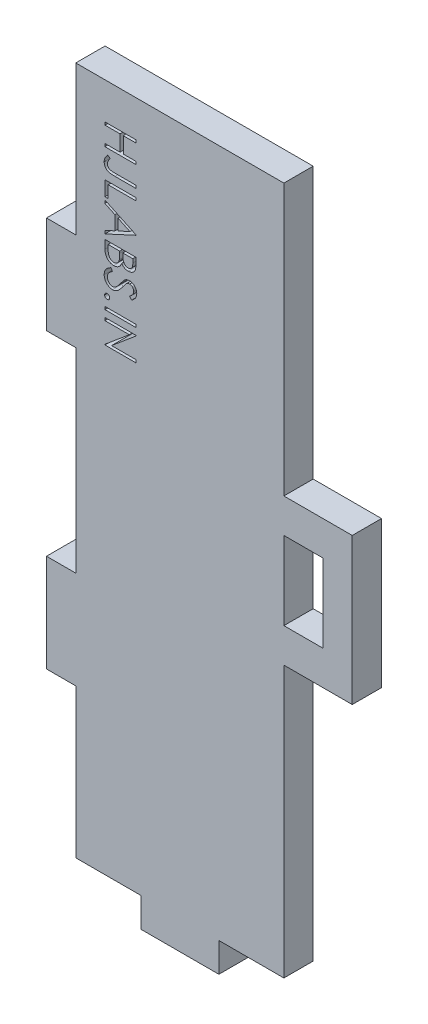
from build123d import *

# Parameters (mm, degrees)
SKETCH1_W           = 4
SKETCH1_H           = 8
BOSS_EXTRUDE1_DEPTH = 3
SKETCH6_W           = 3.175
SKETCH6_H           = 0.284935898
CUT_EXTRUDE2_DEPTH  = 3
SKETCH7_W           = 8
SKETCH7_H           = 3
BOSS_EXTRUDE2_DEPTH = 3


with BuildPart() as part:
    # Sketch1 → Boss-Extrude1 (new body)
    with BuildSketch(Plane.XY):
        Polygon((-24.311841589, 19.25), (-21.311841589, 19.25), (-21.311841589, -0.75), (-24.311841589, -0.75), (-24.311841589, -10.75), (-21.311841589, -10.75), (-21.311841589, -26), (-19.311841589, -26), (-2, -26), (0, -26), (0, 1.75), (7, 1.75), (7, 16.75), (0, 16.75), (0, 44.5), (-2, 44.5), (-19.311841589, 44.5), (-21.311841589, 44.5), (-21.311841589, 29.25), (-24.311841589, 29.25), align=None)
        with Locations((2, 9.25)):
            Rectangle(SKETCH1_W, SKETCH1_H, mode=Mode.SUBTRACT)
    extrude(amount=BOSS_EXTRUDE1_DEPTH)

    # Sketch6 → Cut-Extrude2 (cut)
    with BuildSketch(Plane.XY.offset(3)):
        Polygon((-15.146593803, 40.762402334), (-15.146593803, 40.477466437), (-16.449157905, 40.477466437), (-16.449157905, 38.849261309), (-15.146593803, 38.849261309), (-15.146593803, 38.564325411), (-18.321593803, 38.564325411), (-18.321593803, 38.849261309), (-16.774798931, 38.849261309), (-16.774798931, 40.477466437), (-18.321593803, 40.477466437), (-18.321593803, 40.762402334), align=None)
        with BuildLine():
            Line((-15.146593803, 36.732594642), (-15.146593803, 36.447658745))
            Line((-15.146593803, 36.447658745), (-17.290609227, 36.447658745))
            add(Edge.make_bspline(
                [(-17.290609227, 36.447658745), (-17.330256371, 36.447941117), (-17.406383724, 36.448483308), (-17.516029536, 36.451521507), (-17.616165112, 36.456980275), (-17.706916062, 36.465421839), (-17.788266276, 36.475147508), (-17.860486348, 36.487764385), (-17.923217614, 36.502682774), (-17.99362352, 36.525281608), (-18.071094596, 36.562131291), (-18.154094048, 36.618630687), (-18.227288813, 36.687655753), (-18.290615692, 36.767815595), (-18.341115688, 36.859548851), (-18.377357691, 36.961061014), (-18.399466395, 37.071700873), (-18.401801173, 37.148444623), (-18.403004059, 37.187983264)],
                knots=[0, 0, 0, 0, 0.000118942, 0.000228383, 0.000329037, 0.000419729, 0.000501773, 0.00057476, 0.00063955, 0.000695062, 0.000796347, 0.000895665, 0.000995106, 0.001097022, 0.001200928, 0.001307758, 0.00141927, 0.001537776, 0.001537776, 0.001537776, 0.001537776], degree=3))
            add(Edge.make_bspline(
                [(-18.403004059, 37.187983264), (-18.402055378, 37.219005494), (-18.400159525, 37.281000581), (-18.383770011, 37.373392277), (-18.359467235, 37.465306663), (-18.322718594, 37.557356332), (-18.273584158, 37.651488172), (-18.208969796, 37.749059064), (-18.129306243, 37.851228826), (-18.068491626, 37.918523007), (-18.036657905, 37.953748488)],
                knots=[0, 0, 0, 0, 9.2998e-05, 0.000185848, 0.000280734, 0.000377818, 0.000482504, 0.000598756, 0.000728394, 0.000870794, 0.000870794, 0.000870794, 0.000870794], degree=3))
            Line((-18.036657905, 37.953748488), (-17.792427136, 37.785839834))
            add(Edge.make_bspline(
                [(-17.792427136, 37.785839834), (-17.81909048, 37.747072521), (-17.869331986, 37.67402361), (-17.934848734, 37.566898954), (-17.989919083, 37.471326054), (-18.018412739, 37.408890418), (-18.031569764, 37.380060588)],
                knots=[0, 0, 0, 0, 0.000141121, 0.000265914, 0.000376678, 0.0004717, 0.0004717, 0.0004717, 0.0004717], degree=3))
            add(Edge.make_bspline(
                [(-18.031569764, 37.380060588), (-18.038427272, 37.362566962), (-18.051876372, 37.328258067), (-18.066885865, 37.275802459), (-18.075088623, 37.223646247), (-18.076613832, 37.189068053), (-18.077363034, 37.172082823)],
                knots=[0, 0, 0, 0, 5.6351e-05, 0.000110517, 0.000163322, 0.000214303, 0.000214303, 0.000214303, 0.000214303], degree=3))
            add(Edge.make_bspline(
                [(-18.077363034, 37.172082823), (-18.076464414, 37.150137454), (-18.074696621, 37.106965815), (-18.058149486, 37.044071193), (-18.033889336, 36.983615137), (-17.997485534, 36.928089252), (-17.9544811, 36.877038154), (-17.902471274, 36.83483933), (-17.844634614, 36.799948039), (-17.790324267, 36.777897586), (-17.740406505, 36.764599203), (-17.694730457, 36.755790989), (-17.641119468, 36.749416413), (-17.579911119, 36.742548324), (-17.510685412, 36.738848676), (-17.433760947, 36.734533594), (-17.34891625, 36.732997556), (-17.289760825, 36.732733045), (-17.258808346, 36.732594642)],
                knots=[0, 0, 0, 0, 6.5707e-05, 0.000129261, 0.000193988, 0.00026033, 0.000327522, 0.000393484, 0.000460239, 0.000529568, 0.000568448, 0.000615099, 0.00066898, 0.000730369, 0.000799837, 0.00087689, 0.000961502, 0.001054363, 0.001054363, 0.001054363, 0.001054363], degree=3))
            Line((-17.258808346, 36.732594642), (-15.146593803, 36.732594642))
        make_face()
        Polygon((-15.146593803, 35.63355618), (-15.146593803, 35.348620283), (-17.995952777, 35.348620283), (-17.995952777, 34.127466437), (-18.321593803, 34.127466437), (-18.321593803, 35.63355618), align=None)
        Polygon((-15.146593803, 32.295735668), (-18.321593803, 30.830351052), (-18.321593803, 31.140091637), (-17.303965598, 31.609472647), (-17.303965598, 33.048780539), (-18.321593803, 33.531517919), (-18.321593803, 33.842530539), (-15.146593803, 32.336440796), align=None)
        Polygon((-15.765438955, 32.31926832), (-16.978324572, 32.894228256), (-16.978324572, 31.759572807), align=None, mode=Mode.SUBTRACT)
        with BuildLine():
            Line((-15.146593803, 30.341889514), (-15.146593803, 29.722408344))
            add(Edge.make_bspline(
                [(-15.146593803, 29.722408344), (-15.146753234, 29.692083939), (-15.14706225, 29.633307694), (-15.151854805, 29.547837201), (-15.158389562, 29.467782922), (-15.168758289, 29.393121643), (-15.181269401, 29.323887863), (-15.196420334, 29.259872935), (-15.214587334, 29.201280422), (-15.243476461, 29.131328154), (-15.286405335, 29.051571554), (-15.349840533, 28.965213012), (-15.427430696, 28.891367738), (-15.514954248, 28.827698722), (-15.611234555, 28.777079135), (-15.713976819, 28.740458415), (-15.821855828, 28.717273771), (-15.895917854, 28.714889405), (-15.933347609, 28.713684386)],
                knots=[0, 0, 0, 0, 9.0959e-05, 0.000176302, 0.000256745, 0.000331852, 0.000402335, 0.000467743, 0.000529095, 0.000586142, 0.000694565, 0.000800018, 0.00090617, 0.001014562, 0.001123809, 0.001231237, 0.001341005, 0.001453163, 0.001453163, 0.001453163, 0.001453163], degree=3))
            add(Edge.make_bspline(
                [(-15.933347609, 28.713684386), (-15.96841694, 28.714656924), (-16.037331482, 28.716568054), (-16.137964258, 28.735465339), (-16.234152744, 28.7636007), (-16.324711134, 28.804444931), (-16.408475558, 28.856983252), (-16.484948206, 28.920207057), (-16.552275828, 28.995483263), (-16.589758719, 29.051972556), (-16.60879833, 29.080666557)],
                knots=[0, 0, 0, 0, 0.000105099, 0.000206529, 0.000306133, 0.000405196, 0.000503491, 0.000601945, 0.000701931, 0.00080515, 0.00080515, 0.00080515, 0.00080515], degree=3))
            add(Edge.make_bspline(
                [(-16.60879833, 29.080666557), (-16.622635179, 29.044592129), (-16.649108498, 28.975572811), (-16.696167685, 28.880524818), (-16.746774708, 28.798306195), (-16.802332621, 28.728826443), (-16.862967023, 28.670300504), (-16.927463745, 28.617742996), (-16.99899805, 28.573711588), (-17.075533049, 28.535884897), (-17.15653158, 28.506115688), (-17.241623207, 28.485052019), (-17.32985645, 28.47210942), (-17.389996372, 28.470344567), (-17.420356824, 28.469453616)],
                knots=[0, 0, 0, 0, 0.000115862, 0.000221672, 0.000317675, 0.000404986, 0.000487741, 0.000570085, 0.000654088, 0.000739136, 0.000825861, 0.000912399, 0.001001716, 0.001092775, 0.001092775, 0.001092775, 0.001092775], degree=3))
            add(Edge.make_bspline(
                [(-17.420356824, 28.469453616), (-17.451350882, 28.470340033), (-17.51233256, 28.472084084), (-17.601920085, 28.484943372), (-17.687522418, 28.50673766), (-17.769748205, 28.536684203), (-17.848132018, 28.575990279), (-17.923655549, 28.622793574), (-17.994306902, 28.679759115), (-18.061766244, 28.743255274), (-18.122384589, 28.815171504), (-18.176351748, 28.89275223), (-18.220937809, 28.977113318), (-18.257923037, 29.066946549), (-18.286586399, 29.16284887), (-18.306485834, 29.264464697), (-18.319925319, 29.371816112), (-18.321028205, 29.445485488), (-18.321593803, 29.483265716)],
                knots=[0, 0, 0, 0, 9.2965e-05, 0.000182912, 0.000270839, 0.000357564, 0.000444886, 0.000533473, 0.000623565, 0.000716687, 0.000810992, 0.0009052, 0.000999667, 0.001096636, 0.001196239, 0.001299394, 0.001406999, 0.001520275, 0.001520275, 0.001520275, 0.001520275], degree=3))
            Line((-18.321593803, 29.483265716), (-18.321593803, 30.341889514))
            Line((-18.321593803, 30.341889514), (-15.146593803, 30.341889514))
        make_face()
        with BuildLine():
            Line((-15.472234828, 30.056953616), (-16.489863034, 30.056953616))
            Line((-16.489863034, 30.056953616), (-16.489863034, 29.86551231))
            add(Edge.make_bspline(
                [(-16.489863034, 29.86551231), (-16.489503265, 29.837527794), (-16.488808119, 29.783456005), (-16.486754095, 29.704943434), (-16.481254599, 29.632247438), (-16.475437973, 29.565117519), (-16.46648156, 29.504003612), (-16.455521428, 29.448701124), (-16.444031419, 29.398713265), (-16.424436042, 29.341092486), (-16.395769755, 29.275751287), (-16.350235919, 29.206537817), (-16.297475052, 29.144529828), (-16.235473139, 29.092753938), (-16.167780787, 29.050029779), (-16.09439196, 29.021517529), (-16.018171733, 29.001294165), (-15.965708514, 28.999520707), (-15.939071768, 28.998620283)],
                knots=[0, 0, 0, 0, 8.3964e-05, 0.000162235, 0.000235554, 0.000302638, 0.000364342, 0.000420722, 0.000471782, 0.000518041, 0.000603156, 0.000685012, 0.000765726, 0.00084651, 0.000926469, 0.001004655, 0.001081939, 0.001161647, 0.001161647, 0.001161647, 0.001161647], degree=3))
            add(Edge.make_bspline(
                [(-15.939071768, 28.998620283), (-15.921441518, 28.999070623), (-15.886857858, 28.999954014), (-15.83663704, 29.007993922), (-15.788799938, 29.019659906), (-15.744446774, 29.037885732), (-15.702316904, 29.059924523), (-15.664281597, 29.088592991), (-15.628257053, 29.120969412), (-15.595566003, 29.158992367), (-15.566274695, 29.202477746), (-15.540500912, 29.251839886), (-15.520169816, 29.307668196), (-15.50193174, 29.368696831), (-15.489276503, 29.435902501), (-15.478695039, 29.508628516), (-15.473316189, 29.587491831), (-15.472603322, 29.642051872), (-15.472234828, 29.670254898)],
                knots=[0, 0, 0, 0, 5.2851e-05, 0.000103672, 0.000152264, 0.000200215, 0.000247169, 0.000294491, 0.000342665, 0.000392266, 0.000444482, 0.000499669, 0.000558849, 0.000622451, 0.000690555, 0.000763772, 0.000842846, 0.000927458, 0.000927458, 0.000927458, 0.000927458], degree=3))
            Line((-15.472234828, 29.670254898), (-15.472234828, 30.056953616))
        make_face(mode=Mode.SUBTRACT)
        with BuildLine():
            Line((-16.815504059, 30.056953616), (-17.995952777, 30.056953616))
            Line((-17.995952777, 30.056953616), (-17.995952777, 29.65117437))
            add(Edge.make_bspline(
                [(-17.995952777, 29.65117437), (-17.995605879, 29.622128486), (-17.994937279, 29.566146373), (-17.992730751, 29.485320746), (-17.987817139, 29.410609941), (-17.979806642, 29.341970967), (-17.971483037, 29.278799614), (-17.959962766, 29.221723491), (-17.946865611, 29.170655097), (-17.926597142, 29.111447524), (-17.895163465, 29.044733185), (-17.847459494, 28.972888559), (-17.791375914, 28.908375034), (-17.725648023, 28.854219161), (-17.654721262, 28.809499364), (-17.578966601, 28.778134762), (-17.500695089, 28.757967772), (-17.447190155, 28.755584668), (-17.420356824, 28.754389514)],
                knots=[0, 0, 0, 0, 8.7144e-05, 0.000167958, 0.000242546, 0.000311658, 0.000375251, 0.000433626, 0.000486231, 0.000533296, 0.00062121, 0.000706588, 0.000791309, 0.000876652, 0.000961195, 0.001041871, 0.001121777, 0.001202167, 0.001202167, 0.001202167, 0.001202167], degree=3))
            add(Edge.make_bspline(
                [(-17.420356824, 28.754389514), (-17.403578551, 28.7546338), (-17.370292642, 28.755118431), (-17.321414934, 28.762702092), (-17.273857435, 28.773281793), (-17.228339281, 28.788602111), (-17.184119797, 28.807919789), (-17.141969216, 28.832162743), (-17.100879703, 28.860158762), (-17.048992959, 28.903953786), (-16.989190268, 28.967594294), (-16.930647722, 29.058047768), (-16.883432307, 29.160891175), (-16.863385013, 29.235483466), (-16.853029099, 29.274015916)],
                knots=[0, 0, 0, 0, 5.0282e-05, 9.9752e-05, 0.000148043, 0.000196314, 0.000243585, 0.000292575, 0.000341972, 0.000392542, 0.000496043, 0.000602591, 0.000714445, 0.000833969, 0.000833969, 0.000833969, 0.000833969], degree=3))
            add(Edge.make_bspline(
                [(-16.853029099, 29.274015916), (-16.849894634, 29.289463724), (-16.843098466, 29.322957759), (-16.835929101, 29.377574913), (-16.829497947, 29.440137248), (-16.824865719, 29.510377361), (-16.819893104, 29.588574606), (-16.81802807, 29.674703862), (-16.815751697, 29.768826018), (-16.815588717, 29.834133465), (-16.815504059, 29.868056381)],
                knots=[0, 0, 0, 0, 4.7275e-05, 0.000102503, 0.000165156, 0.000235937, 0.000313659, 0.000400195, 0.000494345, 0.00059611, 0.00059611, 0.00059611, 0.00059611], degree=3))
            Line((-16.815504059, 29.868056381), (-16.815504059, 30.056953616))
        make_face(mode=Mode.SUBTRACT)
        with BuildLine():
            Line((-17.709108827, 28.143812591), (-17.548196367, 27.875413152))
            add(Edge.make_bspline(
                [(-17.548196367, 27.875413152), (-17.589983345, 27.850450179), (-17.670045582, 27.802622088), (-17.778229661, 27.72283764), (-17.870179618, 27.640167071), (-17.94536054, 27.553998175), (-18.004550602, 27.464856923), (-18.046462626, 27.372161388), (-18.072602832, 27.276223945), (-18.075777911, 27.210933407), (-18.077363034, 27.178337831)],
                knots=[0, 0, 0, 0, 0.00014596, 0.000279654, 0.00040257, 0.000516191, 0.000621858, 0.000722343, 0.000820302, 0.000917964, 0.000917964, 0.000917964, 0.000917964], degree=3))
            add(Edge.make_bspline(
                [(-18.077363034, 27.178337831), (-18.076587724, 27.150500462), (-18.075050672, 27.095312812), (-18.060281645, 27.014067105), (-18.037592124, 26.935162026), (-18.005097221, 26.860224785), (-17.965783749, 26.790285901), (-17.918295738, 26.728964517), (-17.865140589, 26.675918762), (-17.805796259, 26.632646465), (-17.742193831, 26.5990539), (-17.676324954, 26.57474539), (-17.608479364, 26.559274486), (-17.562482102, 26.55730535), (-17.53929212, 26.556312591)],
                knots=[0, 0, 0, 0, 8.3437e-05, 0.000165414, 0.000246926, 0.00032927, 0.000409894, 0.000486986, 0.000561194, 0.000634468, 0.000706451, 0.000776277, 0.000844642, 0.000914154, 0.000914154, 0.000914154, 0.000914154], degree=3))
            add(Edge.make_bspline(
                [(-17.53929212, 26.556312591), (-17.512857206, 26.557650001), (-17.45911889, 26.560368761), (-17.379834919, 26.583348032), (-17.301373802, 26.619496992), (-17.252840511, 26.652845962), (-17.227643482, 26.670159746)],
                knots=[0, 0, 0, 0, 7.9176e-05, 0.000160953, 0.000245754, 0.000337316, 0.000337316, 0.000337316, 0.000337316], degree=3))
            add(Edge.make_bspline(
                [(-17.227643482, 26.670159746), (-17.209420974, 26.684334988), (-17.171052803, 26.71418149), (-17.114895698, 26.766203128), (-17.055554183, 26.825658833), (-16.993269232, 26.892845839), (-16.929178323, 26.969099684), (-16.861945473, 27.05285459), (-16.791772744, 27.144544119), (-16.745368203, 27.209162756), (-16.72137345, 27.242575612)],
                knots=[0, 0, 0, 0, 6.9232e-05, 0.000145772, 0.000229422, 0.000321238, 0.000420509, 0.000528183, 0.000643433, 0.000766836, 0.000766836, 0.000766836, 0.000766836], degree=3))
            add(Edge.make_bspline(
                [(-16.72137345, 27.242575612), (-16.697574928, 27.275975781), (-16.652073967, 27.339834361), (-16.584630914, 27.429207966), (-16.522575854, 27.50902049), (-16.466773191, 27.579678618), (-16.414789094, 27.639354334), (-16.369409622, 27.690229216), (-16.328211562, 27.730426297), (-16.301507118, 27.752795024), (-16.289517481, 27.762838031)],
                knots=[0, 0, 0, 0, 0.00012303, 0.000235223, 0.000335855, 0.000426344, 0.000505264, 0.000573246, 0.000630819, 0.000677729, 0.000677729, 0.000677729, 0.000677729], degree=3))
            add(Edge.make_bspline(
                [(-16.289517481, 27.762838031), (-16.270829397, 27.77687384), (-16.234076773, 27.804477142), (-16.176632081, 27.840913447), (-16.117828119, 27.871882545), (-16.05750687, 27.896159803), (-15.996515184, 27.916603373), (-15.934057269, 27.930353782), (-15.870413379, 27.938963835), (-15.827583989, 27.939845565), (-15.806144083, 27.94028695)],
                knots=[0, 0, 0, 0, 7.0095e-05, 0.000137851, 0.00020385, 0.000269165, 0.000332722, 0.000396603, 0.00046074, 0.000525028, 0.000525028, 0.000525028, 0.000525028], degree=3))
            add(Edge.make_bspline(
                [(-15.806144083, 27.94028695), (-15.772549975, 27.939108103), (-15.70607981, 27.936775608), (-15.609028362, 27.916888205), (-15.516087379, 27.885865171), (-15.429304066, 27.84099678), (-15.348881368, 27.785522836), (-15.276048011, 27.719961347), (-15.214297953, 27.642121511), (-15.16097141, 27.556239953), (-15.118867875, 27.462842613), (-15.086938627, 27.365148786), (-15.069088222, 27.262730079), (-15.066497894, 27.193243266), (-15.065183546, 27.157985267)],
                knots=[0, 0, 0, 0, 0.000100692, 0.000199231, 0.000295975, 0.000393825, 0.00049121, 0.000588457, 0.000686595, 0.000788262, 0.00089101, 0.00099319, 0.001095873, 0.001201643, 0.001201643, 0.001201643, 0.001201643], degree=3))
            add(Edge.make_bspline(
                [(-15.065183546, 27.157985267), (-15.06644983, 27.120565399), (-15.068961023, 27.046357326), (-15.091577016, 26.936995769), (-15.128109005, 26.831500705), (-15.170184996, 26.746582348), (-15.212020512, 26.680236526), (-15.250141212, 26.629643567), (-15.29402354, 26.578373905), (-15.343788951, 26.52601546), (-15.399892719, 26.473454982), (-15.461951008, 26.419912286), (-15.529584449, 26.365262126), (-15.577866676, 26.330105024), (-15.602618442, 26.312081821)],
                knots=[0, 0, 0, 0, 0.000112158, 0.000222422, 0.00033345, 0.000446371, 0.000505835, 0.000568546, 0.000636222, 0.000708201, 0.000785138, 0.00086675, 0.00095406, 0.001045903, 0.001045903, 0.001045903, 0.001045903], degree=3))
            Line((-15.602618442, 26.312081821), (-15.797875854, 26.569668961))
            add(Edge.make_bspline(
                [(-15.797875854, 26.569668961), (-15.777838256, 26.585222771), (-15.739250526, 26.615175772), (-15.68521084, 26.660650381), (-15.635847295, 26.703511646), (-15.592971154, 26.745739535), (-15.554233948, 26.785103672), (-15.521069916, 26.823310129), (-15.493149162, 26.859807513), (-15.463367434, 26.90581884), (-15.433657957, 26.963772171), (-15.409053437, 27.036448604), (-15.39373541, 27.112190574), (-15.391805517, 27.163636632), (-15.390824572, 27.189786148)],
                knots=[0, 0, 0, 0, 7.6089e-05, 0.000146529, 0.000211865, 0.000272136, 0.000327011, 0.000377509, 0.000423812, 0.00046474, 0.000541824, 0.000618456, 0.000694294, 0.00077269, 0.00077269, 0.00077269, 0.00077269], degree=3))
            add(Edge.make_bspline(
                [(-15.390824572, 27.189786148), (-15.391923757, 27.222585279), (-15.394043432, 27.285835314), (-15.417193704, 27.375633599), (-15.453644392, 27.456454517), (-15.504730122, 27.52589863), (-15.565255594, 27.583717173), (-15.634904984, 27.625541411), (-15.711814735, 27.650714774), (-15.765464666, 27.653786614), (-15.792787713, 27.655351052)],
                knots=[0, 0, 0, 0, 9.8196e-05, 0.000189362, 0.000276162, 0.00036267, 0.000446363, 0.000525662, 0.000604507, 0.000686336, 0.000686336, 0.000686336, 0.000686336], degree=3))
            add(Edge.make_bspline(
                [(-15.792787713, 27.655351052), (-15.809793646, 27.654977828), (-15.84383332, 27.65423077), (-15.894256527, 27.644514477), (-15.944232145, 27.630737067), (-15.993982394, 27.610572978), (-16.044677688, 27.583412856), (-16.096181156, 27.546483255), (-16.149793135, 27.500282804), (-16.184627557, 27.464822974), (-16.203019083, 27.446101253)],
                knots=[0, 0, 0, 0, 5.0945e-05, 0.000101973, 0.000153518, 0.000206311, 0.000262656, 0.00032565, 0.000396016, 0.00047472, 0.00047472, 0.00047472, 0.00047472], degree=3))
            add(Edge.make_bspline(
                [(-16.203019083, 27.446101253), (-16.209221242, 27.439151293), (-16.223956153, 27.422639781), (-16.24807915, 27.392453763), (-16.277835951, 27.352591367), (-16.314654445, 27.304093513), (-16.357364057, 27.246065978), (-16.405418691, 27.178502381), (-16.460378357, 27.102155847), (-16.498802698, 27.047979538), (-16.519119844, 27.019333424)],
                knots=[0, 0, 0, 0, 2.7941e-05, 6.6382e-05, 0.000115865, 0.000177177, 0.00024905, 0.000332006, 0.000425904, 0.000531263, 0.000531263, 0.000531263, 0.000531263], degree=3))
            add(Edge.make_bspline(
                [(-16.519119844, 27.019333424), (-16.544194506, 26.984874774), (-16.592748114, 26.918150374), (-16.665696624, 26.823210998), (-16.737041385, 26.737128758), (-16.806326786, 26.659601423), (-16.87302727, 26.589863085), (-16.937945298, 26.528687438), (-17.000615782, 26.475451143), (-17.080963761, 26.418138566), (-17.179643745, 26.359575401), (-17.300546147, 26.309282034), (-17.421918523, 26.277569819), (-17.503495011, 26.273422801), (-17.543744244, 26.271376693)],
                knots=[0, 0, 0, 0, 0.000127846, 0.000247556, 0.00035912, 0.000463173, 0.000559432, 0.00064852, 0.000730687, 0.00080588, 0.000944415, 0.001073869, 0.001197738, 0.001318375, 0.001318375, 0.001318375, 0.001318375], degree=3))
            add(Edge.make_bspline(
                [(-17.543744244, 26.271376693), (-17.572208679, 26.271973143), (-17.628584789, 26.273154459), (-17.711369444, 26.286721329), (-17.791758168, 26.306623506), (-17.868830127, 26.336525925), (-17.943616608, 26.373308725), (-18.015428721, 26.418740762), (-18.083279275, 26.473509053), (-18.148580232, 26.534381791), (-18.207565769, 26.602031635), (-18.260321726, 26.673361921), (-18.304478131, 26.748835734), (-18.340024151, 26.828087772), (-18.368265647, 26.910679628), (-18.388565045, 26.996698222), (-18.401052196, 27.086383089), (-18.402346175, 27.147344063), (-18.403004059, 27.178337831)],
                knots=[0, 0, 0, 0, 8.5312e-05, 0.000168967, 0.000251033, 0.000333365, 0.00041642, 0.000500762, 0.000587675, 0.000677662, 0.000768247, 0.000856532, 0.000943472, 0.001030007, 0.001116695, 0.001204937, 0.001294795, 0.001387732, 0.001387732, 0.001387732, 0.001387732], degree=3))
            add(Edge.make_bspline(
                [(-18.403004059, 27.178337831), (-18.402535031, 27.202317405), (-18.401602882, 27.249974556), (-18.393557312, 27.320276038), (-18.381758387, 27.389286572), (-18.3637693, 27.456139648), (-18.34142971, 27.521667706), (-18.314078115, 27.585286651), (-18.281517432, 27.647151047), (-18.243693728, 27.707333136), (-18.200103243, 27.766400004), (-18.149728087, 27.824048835), (-18.092916212, 27.880939134), (-18.029084998, 27.936028016), (-17.958916416, 27.990330913), (-17.881822524, 28.042837963), (-17.798203519, 28.094618365), (-17.739361758, 28.127108234), (-17.709108827, 28.143812591)],
                knots=[0, 0, 0, 0, 7.1915e-05, 0.000142924, 0.000212043, 0.000281773, 0.00035036, 0.000419592, 0.000489294, 0.00055988, 0.000632642, 0.000709287, 0.000789339, 0.000873642, 0.000962058, 0.001055381, 0.001153341, 0.001257002, 0.001257002, 0.001257002, 0.001257002], degree=3))
        make_face()
        with BuildLine():
            add(Edge.make_bspline(
                [(-17.833132264, 25.396216437), (-17.834148169, 25.378523793), (-17.836128024, 25.344043349), (-17.850678969, 25.294114623), (-17.875230603, 25.24848878), (-17.908964799, 25.208098883), (-17.94923884, 25.174529703), (-17.994748781, 25.149695568), (-18.044822257, 25.134477647), (-18.079800089, 25.132596579), (-18.097715598, 25.131633104)],
                knots=[0, 0, 0, 0, 5.3034e-05, 0.000103356, 0.000154574, 0.000207425, 0.000260276, 0.000310934, 0.000362045, 0.000415713, 0.000415713, 0.000415713, 0.000415713], degree=3))
            add(Edge.make_bspline(
                [(-18.097715598, 25.131633104), (-18.115200321, 25.132635068), (-18.149739461, 25.134614338), (-18.199434051, 25.149663973), (-18.244974252, 25.174724142), (-18.285795811, 25.207869756), (-18.319602222, 25.248498608), (-18.343934932, 25.29422493), (-18.359504049, 25.343923653), (-18.361352239, 25.378503651), (-18.362298931, 25.396216437)],
                knots=[0, 0, 0, 0, 5.2401e-05, 0.000103513, 0.000154171, 0.000207513, 0.000260364, 0.000311582, 0.000362084, 0.000415118, 0.000415118, 0.000415118, 0.000415118], degree=3))
            add(Edge.make_bspline(
                [(-18.362298931, 25.396216437), (-18.361316699, 25.413916469), (-18.359387844, 25.448674848), (-18.344245833, 25.498559775), (-18.319368942, 25.544009307), (-18.285858295, 25.584646072), (-18.244762784, 25.617516387), (-18.199744092, 25.643731046), (-18.149595908, 25.657576412), (-18.115172047, 25.65971519), (-18.097715598, 25.66079977)],
                knots=[0, 0, 0, 0, 5.3034e-05, 0.000104146, 0.000154804, 0.000207655, 0.000260997, 0.000311962, 0.000362895, 0.000415296, 0.000415296, 0.000415296, 0.000415296], degree=3))
            add(Edge.make_bspline(
                [(-18.097715598, 25.66079977), (-18.079829373, 25.659750738), (-18.044968168, 25.657706118), (-17.994438866, 25.643698938), (-17.949448292, 25.617714419), (-17.908902941, 25.584416401), (-17.875463134, 25.544019293), (-17.850372778, 25.498666995), (-17.83624251, 25.448557214), (-17.834182887, 25.413896844), (-17.833132264, 25.396216437)],
                knots=[0, 0, 0, 0, 5.3667e-05, 0.0001046, 0.000155565, 0.000208416, 0.000261267, 0.000311925, 0.000362858, 0.000415892, 0.000415892, 0.000415892, 0.000415892], degree=3))
        make_face()
        with Locations((-16.734093803, 24.256472847)):
            Rectangle(SKETCH6_W, SKETCH6_H)
        Polygon((-18.321593803, 23.422017719), (-15.146593803, 23.422017719), (-15.146593803, 23.362232062), (-17.645507064, 21.264645924), (-15.146593803, 21.264645924), (-15.146593803, 20.979710027), (-18.321593803, 20.979710027), (-18.321593803, 21.044583825), (-15.8284047, 23.137081821), (-18.321593803, 23.137081821), align=None)
    extrude(amount=-CUT_EXTRUDE2_DEPTH, mode=Mode.SUBTRACT)

    # Sketch7 → Boss-Extrude2 (add)
    with BuildSketch(Plane.XY.offset(3)):
        with Locations((-10.655920795, -27.5)):
            Rectangle(SKETCH7_W, SKETCH7_H)
    extrude(amount=-BOSS_EXTRUDE2_DEPTH)


solid = part.part
